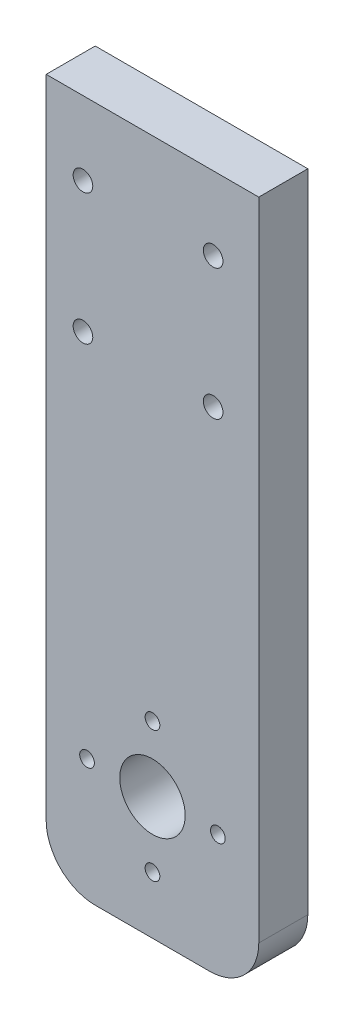
from build123d import *

# Parameters (mm, degrees)
ESQUISSE1_R             = 0.9
ESQUISSE1_R_2           = 4
BOSS_EXTRU_1_DEPTH      = 6
ESQUISSE2_R             = 1.2
ENL_V_MAT_EXTRU_1_DEPTH = 10


with BuildPart() as part:
    # Esquisse1 → Boss.-Extru.1 (new body)
    with BuildSketch(Plane.XY):
        with BuildLine():
            Line((24.916434397, -77.573457495), (24.916434397, 1.426542505))
            Line((24.916434397, 1.426542505), (50.916434397, 1.426542505))
            Line((50.916434397, 1.426542505), (50.916434397, -77.573457495))
            ThreePointArc((50.916434397, -77.573457495), (49.159075085, -81.816098182), (44.916434397, -83.573457495))
            Line((44.916434397, -83.573457495), (30.916434397, -83.573457495))
            ThreePointArc((30.916434397, -83.573457495), (26.67379371, -81.816098182), (24.916434397, -77.573457495))
        make_face()
        with Locations((29.916434397, -68.573457495)):
            Circle(ESQUISSE1_R, mode=Mode.SUBTRACT)
        with Locations((37.916434397, -60.573457495)):
            Circle(ESQUISSE1_R, mode=Mode.SUBTRACT)
        with Locations((45.916434397, -68.573457495)):
            Circle(ESQUISSE1_R, mode=Mode.SUBTRACT)
        with Locations((37.916434397, -76.573457495)):
            Circle(ESQUISSE1_R, mode=Mode.SUBTRACT)
        with Locations((37.916434397, -68.573457495)):
            Circle(ESQUISSE1_R_2, mode=Mode.SUBTRACT)
    extrude(amount=BOSS_EXTRU_1_DEPTH)

    # Esquisse2 → Enlèv. mat.-Extru.1 (cut)
    with BuildSketch(Plane(origin=(0, 0, 0), x_dir=(-1, 0, 0), z_dir=(0, 0, -1))):
        with Locations((-45.336434397, -7.573457495)):
            Circle(ESQUISSE2_R)
        with Locations((-29.416434397, -7.573457495)):
            Circle(ESQUISSE2_R)
        with Locations((-45.336434397, -23.573457495)):
            Circle(ESQUISSE2_R)
        with Locations((-29.416434397, -23.573457495)):
            Circle(ESQUISSE2_R)
    extrude(amount=-ENL_V_MAT_EXTRU_1_DEPTH, mode=Mode.SUBTRACT)


solid = part.part
